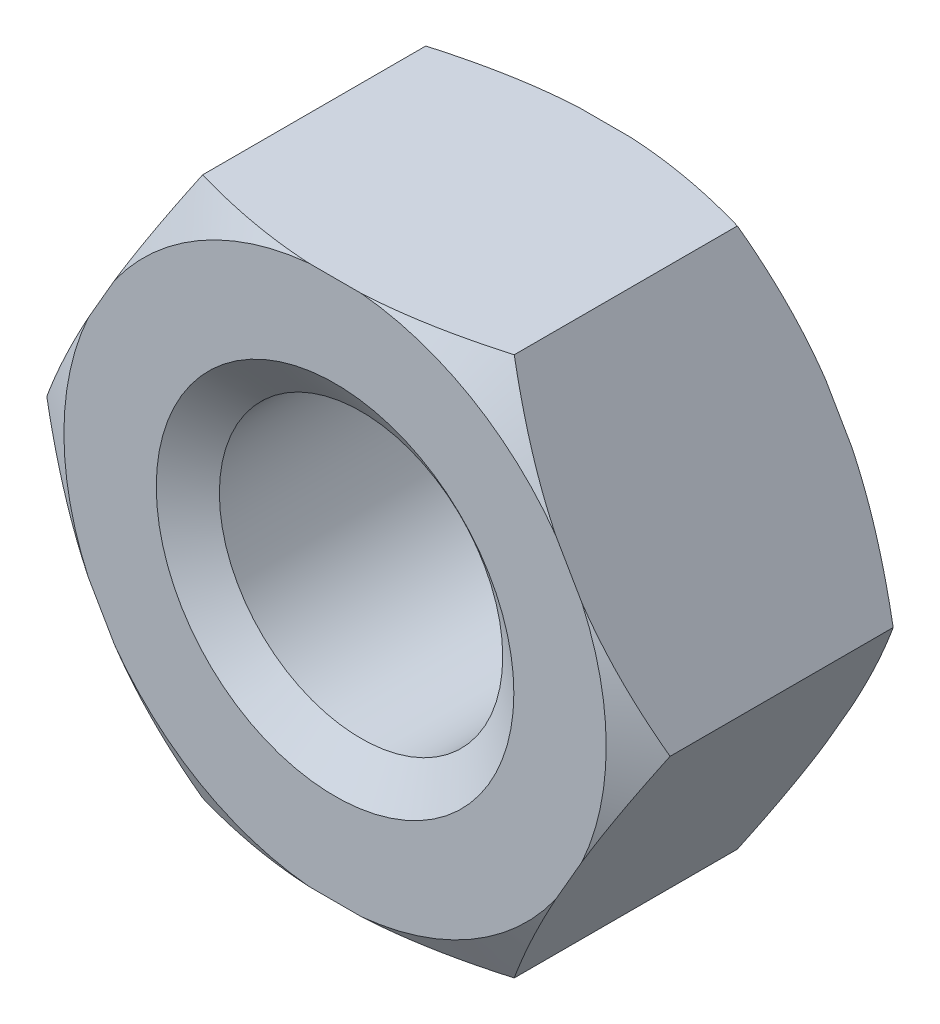
from build123d import *

# Parameters (mm, degrees)
EXTRUDE_1_DEPTH = 4


with BuildPart() as part:
    # Эскиз1 → Бобышка-Вытянуть1 (new body)
    with BuildSketch(Plane.XY):
        Polygon((4.618802154, 0), (2.309401077, 4), (-2.309401077, 4), (-4.618802154, 0), (-2.309401077, -4), (2.309401077, -4), align=None)
    extrude(amount=EXTRUDE_1_DEPTH)

    # Эскиз2 → Вырез-Повернуть2 (revolve, cut)
    with BuildSketch(Plane(origin=(0, 0, 0), x_dir=(1, 0, 0), z_dir=(0, 1, 0))):
        Polygon((-4.018802154, 0), (-4.018802154, 0.812802913), (-5.016585269, 0.812802913), (-5.016585269, -4.215003636), (-4.018802154, -4.215003636), (-4.018802154, -4), (-4.618802154, -3.653589838), (-4.618802154, -0.346410162), align=None)
    revolve(axis=Axis((0, 0, 0), (0, 0, 1)), mode=Mode.SUBTRACT)

    # Эскиз3 → Отверстие обработанное метчиком M51 (revolve, cut)
    with BuildSketch(Plane.YZ):
        Polygon((0, 0), (0, 4), (2.65, 4), (2.1, 3.614885854), (2.1, 0.385114146), (2.65, 0), align=None)
    revolve(axis=Axis((0, 0, -6.35), (0, 0, 1)), mode=Mode.SUBTRACT)


solid = part.part
